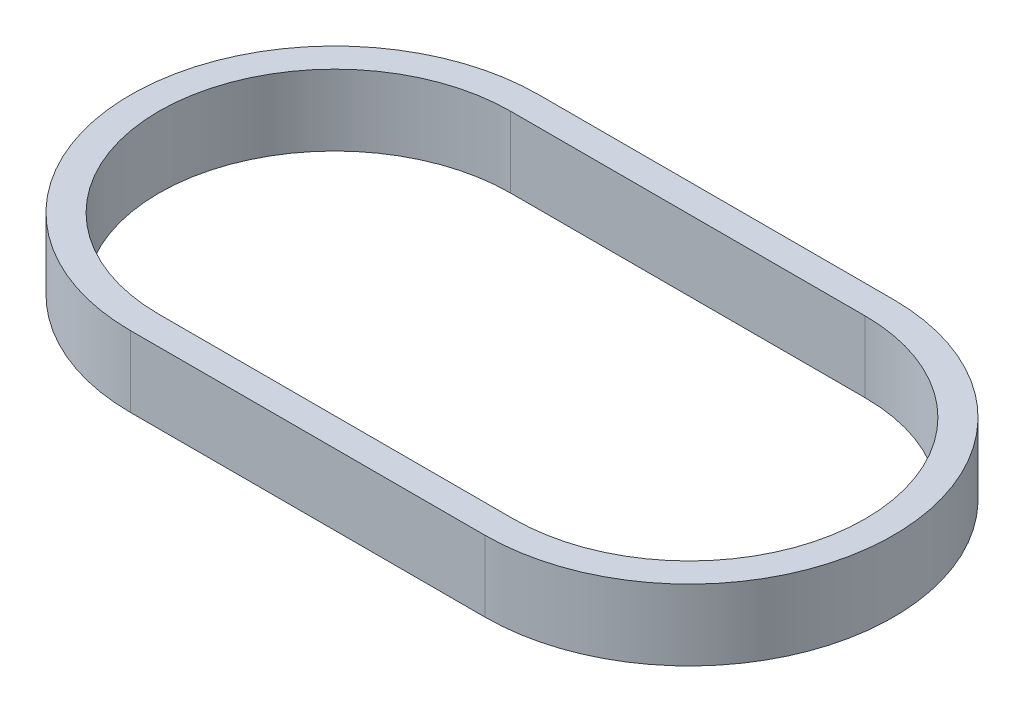
from build123d import *

# Parameters (mm, degrees)
BOSS_EXTRUDE1_DEPTH = 5


with BuildPart() as part:
    # Sketch1 → Boss-Extrude1 (new body)
    with BuildSketch(Plane(origin=(0, 0, 0), x_dir=(1, 0, 0), z_dir=(0, 1, 0))):
        with BuildLine():
            Line((0, 14.4), (25, 14.4))
            ThreePointArc((25, 14.4), (39.4, 0), (25, -14.4))
            Line((25, -14.4), (0, -14.4))
            ThreePointArc((0, -14.4), (-14.4, 0), (0, 14.4))
        make_face()
        with BuildLine():
            Line((0, 12.4), (25, 12.4))
            ThreePointArc((25, 12.4), (37.4, 0), (25, -12.4))
            Line((25, -12.4), (0, -12.4))
            ThreePointArc((0, -12.4), (-12.4, 0), (0, 12.4))
        make_face(mode=Mode.SUBTRACT)
    extrude(amount=BOSS_EXTRUDE1_DEPTH)


solid = part.part
